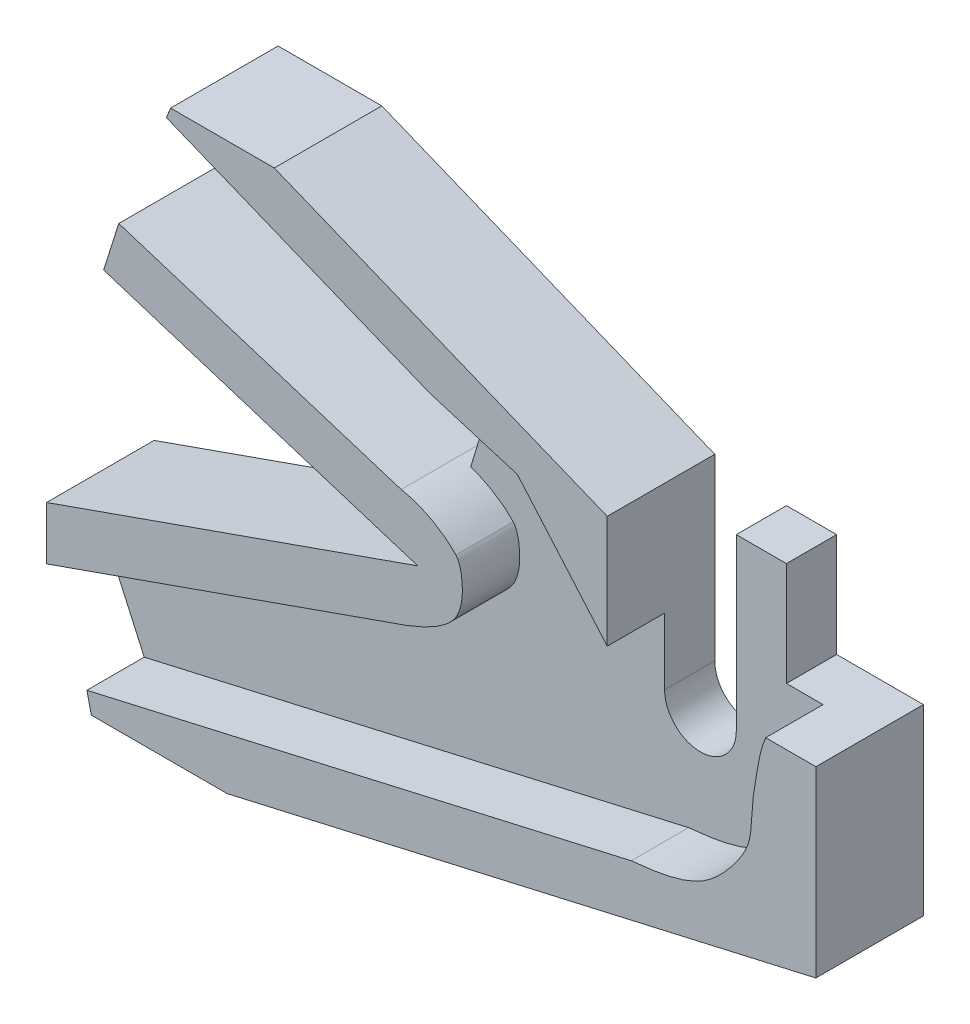
from build123d import *

# Parameters (mm, degrees)
BOSS_EXTRUDE1_DEPTH = 7
BOSS_EXTRUDE2_DEPTH = 15


with BuildPart() as part:
    # Sketch2 → Boss-Extrude1 (new body)
    with BuildSketch(Plane.XY):
        with BuildLine():
            add(Edge.make_bspline(
                [(85.401271326, 166.889749017), (84.935808874, 167.095872385), (84.400736928, 167.300315692), (83.92107701, 167.477529928), (83.850052794, 167.502388403)],
                knots=[0.594155425, 0.594155425, 0.594155425, 0.594155425, 0.769616283, 0.79901036, 0.79901036, 0.79901036, 0.79901036], degree=3))
            Line((85.401271326, 166.889749017), (90.123937612, 180.347267455))
            Line((90.123937612, 180.347267455), (87.946116645, 181.007780929))
            Line((87.946116645, 181.007780929), (85.898084719, 174.255084666))
            Line((85.898084719, 174.255084666), (83.850052794, 167.502388403))
        make_face()
        with BuildLine():
            Line((90.123937612, 180.347267455), (85.401271326, 166.889749017))
            add(Edge.make_bspline(
                [(89.784065302, 163.822842659), (89.316329949, 164.268991095), (88.728382238, 164.883230811), (87.468604966, 165.75600215), (86.505015586, 166.374833097), (85.637598156, 166.78509507), (85.401271326, 166.889749017)],
                knots=[0, 0, 0, 0, 0.219202805, 0.269709764, 0.505069595, 0.594155425, 0.594155425, 0.594155425, 0.594155425], degree=3))
            add(Edge.make_bspline(
                [(79.225262092, 150.588845561), (82.704624356, 151.726727244), (85.475249813, 152.810317388), (88.190973008, 154.560214514), (89.230193626, 155.455562887), (90.308517401, 157.110254117), (90.714109868, 158.947185872), (90.637714337, 162.884305981), (89.924323306, 163.657833243), (89.784065302, 163.822842659)],
                knots=[0, 0, 0, 0, 0.252456109, 0.293916013, 0.401189817, 0.430118649, 0.5542755, 0.612815596, 1, 1, 1, 1], degree=3))
            Line((79.225262092, 150.588845561), (32.682345123, 134.200710217))
            Line((32.682345123, 134.200710217), (38.307485262, 121.747147987))
            Line((38.307485262, 121.747147987), (114.251338293, 139.122057435))
            add(Edge.make_bspline(
                [(114.251338293, 139.122057435), (117.630269236, 139.451745499), (123.500637096, 140.176505625), (128.302839898, 145.268019156), (131.110589529, 149.496362437), (130.976085883, 154.112704049), (131.813514939, 158.698679077), (132.292264245, 161.793379253), (133.003068169, 163.363718022)],
                knots=[0, 0, 0, 0, 0.304997778, 0.465583157, 0.594531522, 0.730666825, 0.852303271, 1, 1, 1, 1], degree=3))
            Line((133.003068169, 163.363718022), (127.895456025, 163.363718022))
            Line((127.895456025, 163.363718022), (127.895456025, 177.847108131))
            Line((127.895456025, 177.847108131), (120.895456025, 177.847108131))
            Line((120.895456025, 177.847108131), (120.895456025, 154.100245399))
            ThreePointArc((120.895456025, 154.100245399), (115.895456025, 149.100245399), (110.895456025, 154.100245399))
            Line((110.895456025, 154.100245399), (110.895456025, 163.363718022))
            Line((110.895456025, 163.363718022), (98.367371866, 177.847108131))
            Line((98.367371866, 177.847108131), (90.123937612, 180.347267455))
        make_face()
        with BuildLine():
            add(Edge.make_bspline(
                [(89.784065302, 163.822842659), (89.316329949, 164.268991095), (88.728382238, 164.883230811), (87.468604966, 165.75600215), (86.505015586, 166.374833097), (85.637598156, 166.78509507), (85.401271326, 166.889749017)],
                knots=[0, 0, 0, 0, 0.219202805, 0.269709764, 0.505069595, 0.594155425, 0.594155425, 0.594155425, 0.594155425], degree=3))
            add(Edge.make_bspline(
                [(85.401271326, 166.889749017), (84.935808874, 167.095872385), (84.400736928, 167.300315692), (83.92107701, 167.477529928), (83.850052794, 167.502388403)],
                knots=[0.594155425, 0.594155425, 0.594155425, 0.594155425, 0.769616283, 0.79901036, 0.79901036, 0.79901036, 0.79901036], degree=3))
            add(Edge.make_bspline(
                [(83.850052794, 167.502388403), (83.80148814, 167.519386032), (83.305559621, 167.686699568), (82.600032514, 167.827100909), (82.151673377, 167.921017402)],
                knots=[0.79901036, 0.79901036, 0.79901036, 0.79901036, 0.819109324, 1, 1, 1, 1], degree=3))
            Line((82.151673377, 167.921017402), (43.171860596, 180.230182782))
            Line((43.171860596, 180.230182782), (42.752039893, 180.362755057))
            Line((42.752039893, 180.362755057), (40.644159119, 173.687664148))
            Line((40.644159119, 173.687664148), (81.691278154, 160.72567843))
            Line((81.691278154, 160.72567843), (84.457109093, 159.852275814))
            Line((84.457109093, 159.852275814), (32.682345123, 141.621965068))
            Line((32.682345123, 141.621965068), (32.682345123, 134.200710217))
            Line((32.682345123, 134.200710217), (79.225262092, 150.588845561))
            add(Edge.make_bspline(
                [(79.225262092, 150.588845561), (82.704624356, 151.726727244), (85.475249813, 152.810317388), (88.190973008, 154.560214514), (89.230193626, 155.455562887), (90.308517401, 157.110254117), (90.714109868, 158.947185872), (90.637714337, 162.884305981), (89.924323306, 163.657833243), (89.784065302, 163.822842659)],
                knots=[0, 0, 0, 0, 0.252456109, 0.293916013, 0.401189817, 0.430118649, 0.5542755, 0.612815596, 1, 1, 1, 1], degree=3))
        make_face()
        Polygon((87.946116645, 181.007780929), (90.123937612, 180.347267455), (98.367371866, 177.847108131), (110.895456025, 177.847108131), (110.895456025, 179.055292265), (64.446548558, 197.916790396), (49.978296282, 197.916790396), (49.392667595, 196.474603116), (86.111411497, 181.564230467), align=None)
        Polygon((110.895456025, 177.847108131), (98.367371866, 177.847108131), (110.895456025, 163.363718022), align=None)
        with BuildLine():
            Line((114.251338293, 139.122057435), (38.307485262, 121.747147987))
            Line((38.307485262, 121.747147987), (38.925280723, 119.04683074))
            Line((38.925280723, 119.04683074), (57.891473285, 119.04683074))
            Line((57.891473285, 119.04683074), (140.003068169, 137.832834725))
            Line((140.003068169, 137.832834725), (140.003068169, 163.363718022))
            Line((140.003068169, 163.363718022), (133.003068169, 163.363718022))
            add(Edge.make_bspline(
                [(114.251338293, 139.122057435), (117.630269236, 139.451745499), (123.500637096, 140.176505625), (128.302839898, 145.268019156), (131.110589529, 149.496362437), (130.976085883, 154.112704049), (131.813514939, 158.698679077), (132.292264245, 161.793379253), (133.003068169, 163.363718022)],
                knots=[0, 0, 0, 0, 0.304997778, 0.465583157, 0.594531522, 0.730666825, 0.852303271, 1, 1, 1, 1], degree=3))
        make_face()
    extrude(amount=BOSS_EXTRUDE1_DEPTH)

    # Sketch2_4 → Boss-Extrude2 (add)
    with BuildSketch(Plane.XY):
        with BuildLine():
            Line((114.251338293, 139.122057435), (38.307485262, 121.747147987))
            Line((38.307485262, 121.747147987), (38.925280723, 119.04683074))
            Line((38.925280723, 119.04683074), (57.891473285, 119.04683074))
            Line((57.891473285, 119.04683074), (140.003068169, 137.832834725))
            Line((140.003068169, 137.832834725), (140.003068169, 163.363718022))
            Line((140.003068169, 163.363718022), (133.003068169, 163.363718022))
            add(Edge.make_bspline(
                [(114.251338293, 139.122057435), (117.630269236, 139.451745499), (123.500637096, 140.176505625), (128.302839898, 145.268019156), (131.110589529, 149.496362437), (130.976085883, 154.112704049), (131.813514939, 158.698679077), (132.292264245, 161.793379253), (133.003068169, 163.363718022)],
                knots=[0, 0, 0, 0, 0.304997778, 0.465583157, 0.594531522, 0.730666825, 0.852303271, 1, 1, 1, 1], degree=3))
        make_face()
        with BuildLine():
            Line((32.682345123, 141.621965068), (32.682345123, 134.200710217))
            Line((32.682345123, 134.200710217), (79.225262092, 150.588845561))
            add(Edge.make_bspline(
                [(79.225262092, 150.588845561), (82.704624356, 151.726727244), (85.475249813, 152.810317388), (88.190973008, 154.560214514), (89.230193626, 155.455562887), (90.308517401, 157.110254117), (90.714109868, 158.947185872), (90.637714337, 162.884305981), (89.924323306, 163.657833243), (89.784065302, 163.822842659)],
                knots=[0, 0, 0, 0, 0.252456109, 0.293916013, 0.401189817, 0.430118649, 0.5542755, 0.612815596, 1, 1, 1, 1], degree=3))
            add(Edge.make_bspline(
                [(89.784065302, 163.822842659), (89.316329949, 164.268991095), (88.728382238, 164.883230811), (87.468604966, 165.75600215), (86.054099361, 166.664417976), (84.609327958, 167.223250049), (83.92107701, 167.477529928), (83.850052794, 167.502388403)],
                knots=[0, 0, 0, 0, 0.219202805, 0.269709764, 0.505069595, 0.769616283, 0.79901036, 0.79901036, 0.79901036, 0.79901036], degree=3))
            add(Edge.make_bspline(
                [(83.850052794, 167.502388403), (83.80148814, 167.519386032), (83.305559621, 167.686699568), (82.600032514, 167.827100909), (82.151673377, 167.921017402)],
                knots=[0.79901036, 0.79901036, 0.79901036, 0.79901036, 0.819109324, 1, 1, 1, 1], degree=3))
            Line((82.151673377, 167.921017402), (43.171860596, 180.230182782))
            Line((43.171860596, 180.230182782), (42.752039893, 180.362755057))
            Line((42.752039893, 180.362755057), (40.644159119, 173.687664148))
            Line((40.644159119, 173.687664148), (81.691278154, 160.72567843))
            Line((81.691278154, 160.72567843), (84.457109093, 159.852275814))
            Line((84.457109093, 159.852275814), (32.682345123, 141.621965068))
        make_face()
        Polygon((64.446548558, 197.916790396), (49.978296282, 197.916790396), (49.392667595, 196.474603116), (86.111411497, 181.564230467), (87.946116645, 181.007780929), (98.367371866, 177.847108131), (110.895456025, 177.847108131), (110.895456025, 179.055292265), align=None)
        Polygon((110.895456025, 163.363718022), (110.895456025, 177.847108131), (98.367371866, 177.847108131), align=None)
    extrude(amount=BOSS_EXTRUDE2_DEPTH)


solid = part.part
